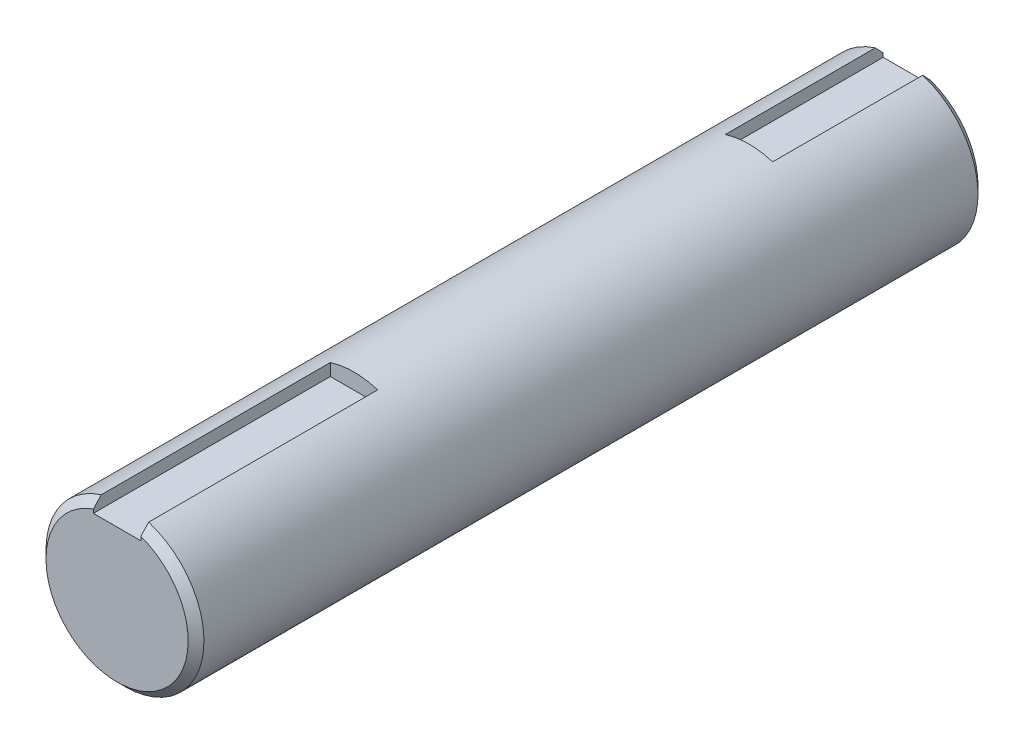
from build123d import *

# Parameters (mm, degrees)
SKETCH1_R           = 10
BOSS_EXTRUDE1_DEPTH = 100
SKETCH2_W           = 6
SKETCH2_H           = 2.85006478
CUT_EXTRUDE1_DEPTH  = 30
SKETCH3_W           = 6
SKETCH3_H           = 2.660897005
CUT_EXTRUDE2_DEPTH  = 20
CHAMFER1_SIZE       = 1


with BuildPart() as part:
    # Sketch1 → Boss-Extrude1 (new body)
    with BuildSketch(Plane.XY):
        Circle(SKETCH1_R)
    extrude(amount=BOSS_EXTRUDE1_DEPTH)

    # Sketch2 → Cut-Extrude1 (cut)
    with BuildSketch(Plane.XY.offset(100)):
        with Locations((0, 9.42503239)):
            Rectangle(SKETCH2_W, SKETCH2_H)
    extrude(amount=-CUT_EXTRUDE1_DEPTH, mode=Mode.SUBTRACT)

    # Sketch3 → Cut-Extrude2 (cut)
    with BuildSketch(Plane(origin=(0, 0, 0), x_dir=(-1, 0, 0), z_dir=(0, 0, -1))):
        with Locations((0, 9.330448503)):
            Rectangle(SKETCH3_W, SKETCH3_H)
    extrude(amount=-CUT_EXTRUDE2_DEPTH, mode=Mode.SUBTRACT)

    # Chamfer1
    chamfer1_edges = [part.edges().sort_by_distance(p)[0] for p in [
        (-5.916079783, -8.062257748, 0),
        (-5.916079783, -8.062257748, 100),
    ]]
    chamfer(chamfer1_edges, length=CHAMFER1_SIZE)


solid = part.part
